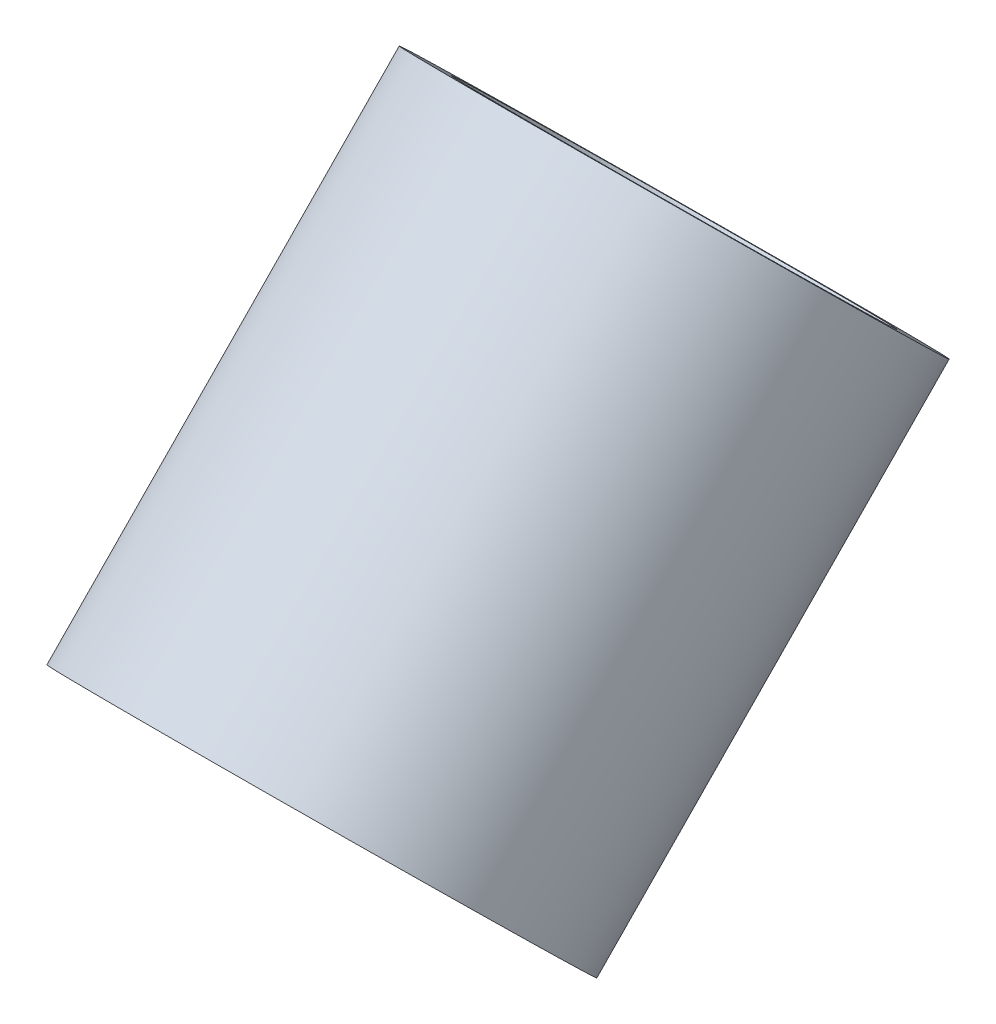
from build123d import *

# Parameters (mm, degrees)
SKETCH3_R           = 25.4
SKETCH3_R_2         = 20.6375
BOSS_EXTRUDE1_DEPTH = 28.575


with BuildPart() as part:
    # Sketch3 → Boss-Extrude1 (new body, symmetric)
    with BuildSketch(Plane(origin=(0, -521.314193807, 510.508576036), x_dir=(1, 0, 0), z_dir=(0, 0.71447268, -0.699663341))):
        with Locations((0, -1433.940917959)):
            Circle(SKETCH3_R)
        with Locations((0, -1433.940917959)):
            Circle(SKETCH3_R_2, mode=Mode.SUBTRACT)
    extrude(amount=BOSS_EXTRUDE1_DEPTH, both=True)


solid = part.part
